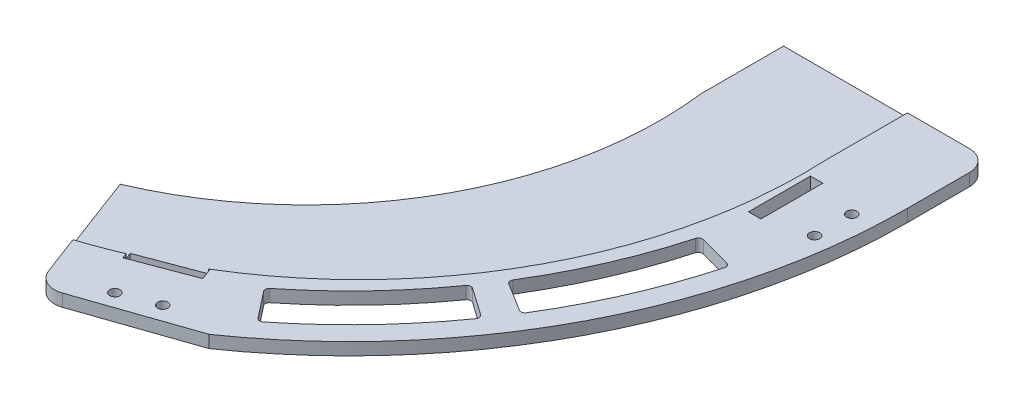
from build123d import *

# Parameters (mm, degrees)
EXTRUDE_2_DEPTH     = 3
CUT_EXTRUDE_1_DEPTH = 3
CUT_EXTRUDE_2_DEPTH = 3
CUT_EXTRUDE_3_DEPTH = 1
SKETCH_16_R         = 85.646074049
CUT_EXTRUDE_6_DEPTH = 10
EXTRUDE_3_DEPTH     = 20
FILLET_1_R          = 5
SKETCH_14_R         = 1.25
SKETCH_14_W         = 3
SKETCH_14_H         = 15
CUT_EXTRUDE_8_DEPTH = 10
CUT_EXTRUDE_9_DEPTH = 10
FILLET_2_R          = 1


with BuildPart() as part:
    # 草图4 → 凸台-拉伸2 (new body)
    with BuildSketch(Plane(origin=(0, 0, 0), x_dir=(1, 0, 0), z_dir=(0, 1, 0))):
        with BuildLine():
            Line((0, 0), (135, 0))
            ThreePointArc((135, 0), (95.45941546, -95.45941546), (0, -135))
            Line((0, -135), (0, 0))
        make_face()
    extrude(amount=EXTRUDE_2_DEPTH)

    # 草图6 → 切除-拉伸1 (cut)
    with BuildSketch(Plane(origin=(0, 3, 0), x_dir=(1, 0, 0), z_dir=(0, 1, 0))):
        with BuildLine():
            Line((0, 0), (85, 0))
            ThreePointArc((85, 0), (69.910657271, -48.347699015), (30, -79.529868603))
            Line((30, -79.529868603), (47.647058824, -126.312144252))
            ThreePointArc((47.647058824, -126.312144252), (24.216322244, -132.810277227), (0, -135))
            Line((0, -135), (0, -18))
            Line((0, -18), (0, 0))
        make_face()
    extrude(amount=-CUT_EXTRUDE_1_DEPTH, mode=Mode.SUBTRACT)

    # 草图8 → 切除-拉伸2 (cut)
    with BuildSketch(Plane(origin=(0, 3, 0), x_dir=(1, 0, 0), z_dir=(0, 1, 0))):
        with BuildLine():
            Line((45.882352941, -121.633916687), (76.908655449, -110.950703995))
            ThreePointArc((76.908655449, -110.950703995), (62.749700806, -119.530226507), (47.647058824, -126.312144252))
            Line((47.647058824, -126.312144252), (45.882352941, -121.633916687))
        make_face()
    extrude(amount=-CUT_EXTRUDE_2_DEPTH, mode=Mode.SUBTRACT)

    # 草图9 → 切除-拉伸3 (cut)
    with BuildSketch(Plane(origin=(0, 3, 0), x_dir=(1, 0, 0), z_dir=(0, 1, 0))):
        with BuildLine():
            Line((40.588235294, -107.599233992), (30, -79.529868603))
            ThreePointArc((30, -79.529868603), (69.910657271, -48.347699015), (85, 0))
            Line((85, 0), (115, 0))
            ThreePointArc((115, 0), (96.045984502, -66.421952411), (40.588235294, -107.599233992))
        make_face()
    extrude(amount=-CUT_EXTRUDE_3_DEPTH, mode=Mode.SUBTRACT)

    # 草图16 → 切除-拉伸6 (cut)
    with BuildSketch(Plane(origin=(0, 2, 0), x_dir=(1, 0, 0), z_dir=(0, 1, 0))):
        with Locations((0, -10.5)):
            Circle(SKETCH_16_R)
    extrude(amount=-CUT_EXTRUDE_6_DEPTH, mode=Mode.SUBTRACT)

    # 草图13 → 凸台-拉伸3 (add)
    with BuildSketch(Plane(origin=(0, 0, 0), x_dir=(-1, 0, 0), z_dir=(0, 0, -1))):
        Polygon((-135, 3), (-135, 0), (-85, 0), (-85, 2), (-115, 2), (-115, 3), align=None)
    extrude(amount=EXTRUDE_3_DEPTH)

    # 圆角1
    fillet_1_edges = [part.edges().sort_by_distance(p)[0] for p in [
        (45.882352941, 1.5, 121.633916687),
        (135, 1.5, -20),
    ]]
    fillet(fillet_1_edges, radius=FILLET_1_R)

    # 草图14 → 切除-拉伸8 (cut)
    with BuildSketch(Plane(origin=(0, 3, 0), x_dir=(1, 0, 0), z_dir=(0, 1, 0))):
        with Locations((129.5, -17)):
            Circle(SKETCH_14_R)
        with Locations((129.5, -8)):
            Circle(SKETCH_14_R)
        with Locations((56.761619346, -113.641470943)):
            Circle(SKETCH_14_R)
        with Locations((65.182428963, -110.465000355)):
            Circle(SKETCH_14_R)
        with Locations((118, -12.5)):
            Rectangle(SKETCH_14_W, SKETCH_14_H)
        Polygon((50.425271043, -105.343839343), (49.366447513, -102.536902804), (63.401130208, -97.242785157), (64.459953737, -100.049721696), align=None)
    extrude(amount=-CUT_EXTRUDE_8_DEPTH, mode=Mode.SUBTRACT)

    # 草图17 → 切除-拉伸9 (cut)
    with BuildSketch(Plane(origin=(0, 3, 0), x_dir=(1, 0, 0), z_dir=(0, 1, 0))):
        with BuildLine():
            Line((115.911099155, -31.058285412), (125.570357418, -33.646475863))
            ThreePointArc((125.570357418, -33.646475863), (119.21780967, -51.83737896), (110.2462525, -68.88950435))
            Line((110.2462525, -68.88950435), (101.765771539, -63.590311708))
            ThreePointArc((101.765771539, -63.590311708), (110.047208926, -47.849888271), (115.911099155, -31.058285412))
        make_face()
        with BuildLine():
            Line((73.879377039, -94.561290433), (80.035991792, -102.441397969))
            ThreePointArc((80.035991792, -102.441397969), (94.298668232, -89.48609484), (106.489765758, -74.564936726))
            Line((106.489765758, -74.564936726), (98.298245315, -68.829172362))
            ThreePointArc((98.298245315, -68.829172362), (87.044924521, -82.602549083), (73.879377039, -94.561290433))
        make_face()
    extrude(amount=-CUT_EXTRUDE_9_DEPTH, mode=Mode.SUBTRACT)

    # 圆角2
    fillet_2_edges = [part.edges().sort_by_distance(p)[0] for p in [
        (73.879377039, 1.5, 94.561290433),
        (98.298245315, 1.5, 68.829172362),
        (106.489765758, 1.5, 74.564936726),
        (80.035991792, 1.5, 102.441397969),
        (101.765771539, 1.5, 63.590311708),
        (115.911099155, 1.5, 31.058285412),
        (125.570357418, 1.5, 33.646475863),
        (110.2462525, 1.5, 68.88950435),
    ]]
    fillet(fillet_2_edges, radius=FILLET_2_R)


solid = part.part
